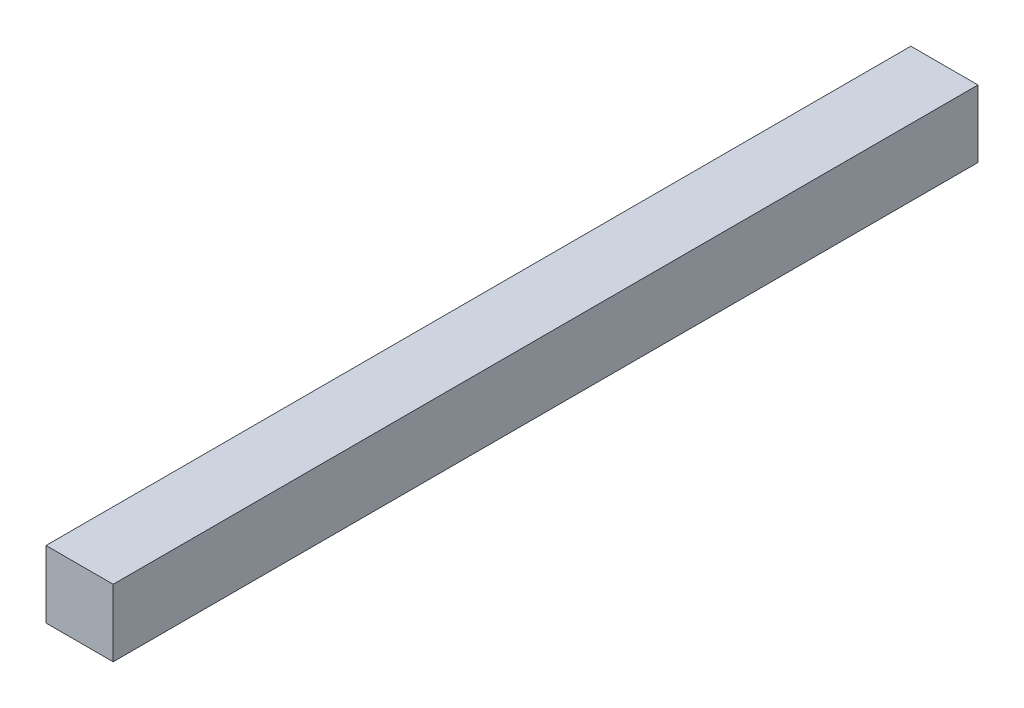
from build123d import *

# Parameters (mm, degrees)
SKETCH1_W           = 25.4
SKETCH1_H           = 25.4
BOSS_EXTRUDE1_DEPTH = 327.025


with BuildPart() as part:
    # Sketch1 → Boss-Extrude1 (new body)
    with BuildSketch(Plane.XY):
        with Locations((12.7, 12.7)):
            Rectangle(SKETCH1_W, SKETCH1_H)
    extrude(amount=BOSS_EXTRUDE1_DEPTH)


solid = part.part
